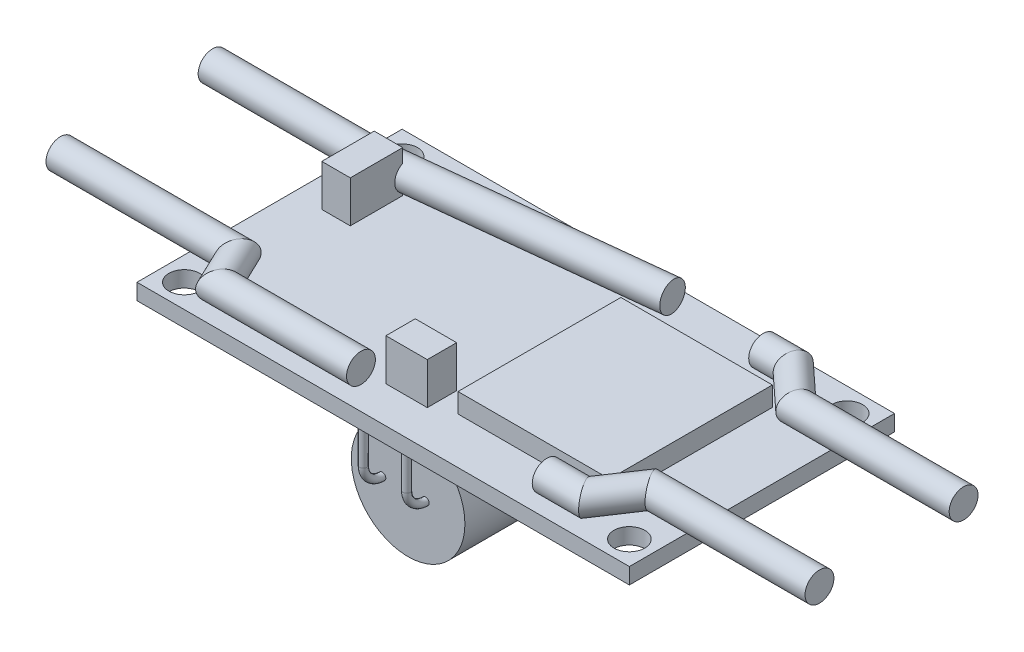
from build123d import *

# Parameters (mm, degrees)
SKETCH1_W             = 52
SKETCH1_H             = 28
BOSS_EXTRUDE1_DEPTH   = 1.6891
SKETCH1_3_R           = 1.63
CUT_EXTRUDE1_DEPTH    = 60.083441494
SKETCH2_R             = 6
BOSS_EXTRUDE2_DEPTH   = 25
SWEEP1_PROFILE_R      = 0.381
LPATTERN1_COUNT       = 2
LPATTERN1_PITCH       = 4.572
SKETCH1_4_W           = 16
SKETCH1_4_H           = 17.2
MOTORCONTROLLER_DEPTH = 2.0574
SKETCH5_W             = 3.0099
SKETCH5_H             = 5.5372
SKETCH5_W_2           = 4.3688
SKETCH5_H_2           = 3.0988
BOSS_EXTRUDE3_DEPTH   = 4.3942
SWEEP2_PROFILE_R      = 1.524
SWEEP3_PROFILE_R      = 1.524
SWEEP4_PROFILE_R      = 1.524
SWEEP6_PROFILE_R      = 1.524


with BuildPart() as part:
    # Sketch1 → Boss-Extrude1 (new body)
    with BuildSketch(Plane(origin=(0, 0, 0), x_dir=(1, 0, 0), z_dir=(0, 1, 0))):
        with Locations((26, 14)):
            Rectangle(SKETCH1_W, SKETCH1_H)
    extrude(amount=-BOSS_EXTRUDE1_DEPTH)

    # Sketch1_3 → Cut-Extrude1 (cut, through all)
    with BuildSketch(Plane(origin=(0, 0, 0), x_dir=(1, 0, 0), z_dir=(0, 1, 0))):
        with Locations((2.5, 25.5)):
            Circle(SKETCH1_3_R)
        with Locations((2.5, 2.5)):
            Circle(SKETCH1_3_R)
        with Locations((49.5, 25.5)):
            Circle(SKETCH1_3_R)
        with Locations((49.5, 2.5)):
            Circle(SKETCH1_3_R)
    extrude(amount=-CUT_EXTRUDE1_DEPTH, mode=Mode.SUBTRACT)



with BuildPart() as body_2:
    # Sketch2 → Boss-Extrude2 (new body)
    with BuildSketch(Plane.XY.offset(-3.4)):
        with Locations((25.2312, -8.1891)):
            Circle(SKETCH2_R)
    extrude(amount=-BOSS_EXTRUDE2_DEPTH)


with BuildPart() as part_1:
    add(part.part)

    add(body_2.part)  # Sweep1 merges body 2
    # Sweep1: sweep along a path in Sketch3
    with BuildLine(Plane.ZY.offset(-22.5)) as sweep1_path:
        Line((-1.4, 0), (-1.4, -6.1891))
        ThreePointArc((-1.4, -6.1891), (-1.985786438, -7.603313562), (-3.4, -8.1891))
    # Sweep1 profile (on start of the path) → Sweep1 (sweep)
    with BuildSketch(Plane(origin=(22.5, 0, -1.4), x_dir=(0, 0, -1), z_dir=(0, -1, 0))):
        Circle(SWEEP1_PROFILE_R)
    sweep1 = sweep(path=sweep1_path.line)

    # LPattern1: Sweep1 ×2
    with Locations(*[(i * LPATTERN1_PITCH, 0, 0) for i in range(1, LPATTERN1_COUNT)]):
        add(sweep1)

    # Sketch1_4 → MotorController (add)
    with BuildSketch(Plane(origin=(0, 0, 0), x_dir=(1, 0, 0), z_dir=(0, 1, 0))):
        with Locations((37, 13.5)):
            Rectangle(SKETCH1_4_W, SKETCH1_4_H)
    extrude(amount=MOTORCONTROLLER_DEPTH)

    # Sketch5 → Boss-Extrude3 (add)
    with BuildSketch(Plane(origin=(0, 0, 0), x_dir=(1, 0, 0), z_dir=(0, 1, 0))):
        with Locations((4.60375, 19.1862)):
            Rectangle(SKETCH5_W, SKETCH5_H)
        with Locations((24.6126, 5.4102)):
            Rectangle(SKETCH5_W_2, SKETCH5_H_2)
    extrude(amount=BOSS_EXTRUDE3_DEPTH)

    # Sweep6: sweep along a path in Sketch4_5
    with BuildLine(Plane(origin=(0, 1.5875, 0), x_dir=(1, 0, 0), z_dir=(0, 1, 0))) as sweep6_path:
        Line((40.856, 2.41), (44.940520364, 2.41))
        Line((44.940520364, 2.41), (47.745694512, 6.618156047))
        Line((47.745694512, 6.618156047), (65.45681083, 6.618156047))
    # Sweep6 profile (on start of the path) → Sweep6 (sweep)
    with BuildSketch(Plane(origin=(40.856, 1.5875, -2.41), x_dir=(0, 0, 1), z_dir=(1, 0, 0))):
        Circle(SWEEP6_PROFILE_R)
    sweep(path=sweep6_path.line, transition=Transition.RIGHT)


with BuildPart() as body_2_2:
    # Sweep2: sweep along a path in Sketch4
    with BuildLine(Plane(origin=(0, 1.5875, 0), x_dir=(1, 0, 0), z_dir=(0, 1, 0))) as sweep2_path:
        Line((31.18115, 25.3771), (2.312530094, 22.233033549))
        Line((2.312530094, 22.233033549), (-14.247884463, 22.233033549))
    # Sweep2 profile (on start of the path) → Sweep2 (sweep)
    with BuildSketch(Plane(origin=(31.18115, 1.5875, -25.3771), x_dir=(-0.10826926941618294, 0, -0.9941216048854818), z_dir=(-0.9941216048854818, 0, 0.10826926941618294))):
        Circle(SWEEP2_PROFILE_R)
    sweep(path=sweep2_path.line, transition=Transition.RIGHT)


with BuildPart() as body_3:
    # Sweep3: sweep along a path in Sketch4_3
    with BuildLine(Plane(origin=(0, 1.5875, 0), x_dir=(1, 0, 0), z_dir=(0, 1, 0))) as sweep3_path:
        Line((21.244, 2.41), (6.265999425, 2.41))
        Line((6.265999425, 2.41), (4.470608354, 6.162))
        Line((4.470608354, 6.162), (-14.247884463, 6.162))
    # Sweep3 profile (on start of the path) → Sweep3 (sweep)
    with BuildSketch(Plane(origin=(21.244, 1.5875, -2.41), x_dir=(0, 0, -1), z_dir=(-1, 0, 0))):
        Circle(SWEEP3_PROFILE_R)
    sweep(path=sweep3_path.line, transition=Transition.RIGHT)


with BuildPart() as body_4:
    # Sweep4: sweep along a path in Sketch4_4
    with BuildLine(Plane(origin=(0, 1.5875, 0), x_dir=(1, 0, 0), z_dir=(0, 1, 0))) as sweep4_path:
        Line((40.856, 25.27), (44.031, 25.27))
        Line((44.031, 25.27), (47.745694512, 21.838))
        Line((47.745694512, 21.838), (65.45681083, 21.838))
    # Sweep4 profile (on start of the path) → Sweep4 (sweep)
    with BuildSketch(Plane(origin=(40.856, 1.5875, -25.27), x_dir=(0, 0, 1), z_dir=(1, 0, 0))):
        Circle(SWEEP4_PROFILE_R)
    sweep(path=sweep4_path.line, transition=Transition.RIGHT)


solid = Compound([part_1.part, body_2_2.part, body_3.part, body_4.part])
